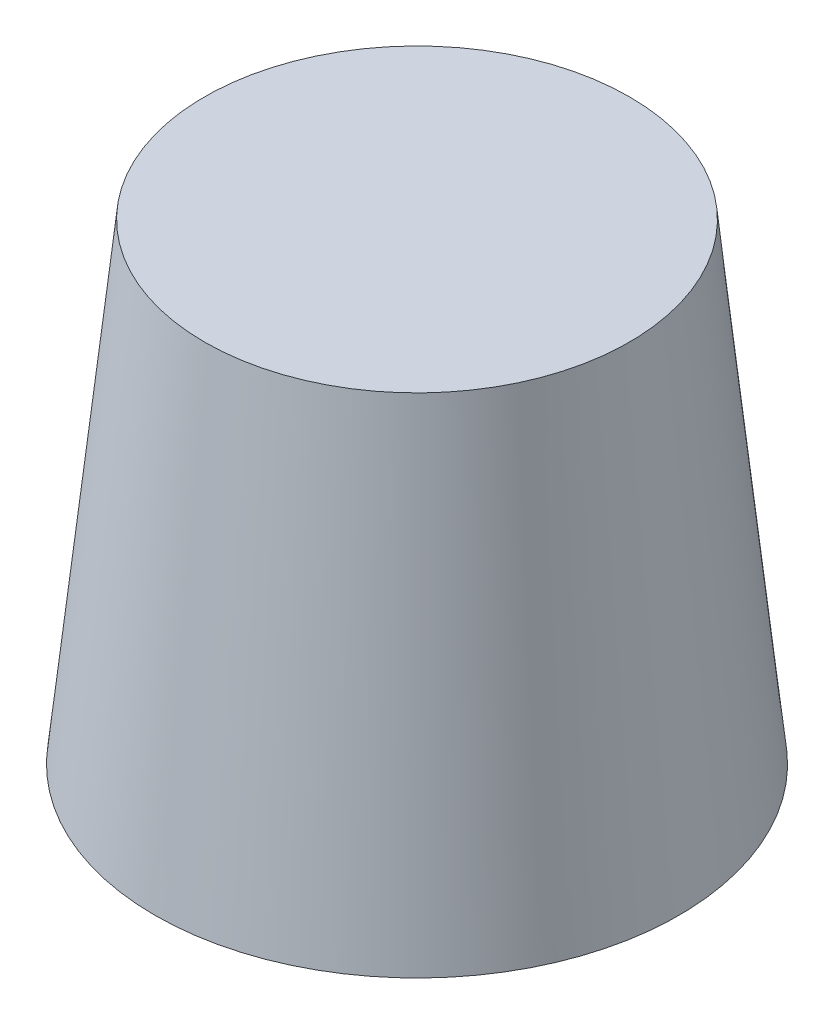
from build123d import *

# Parameters (mm, degrees)
ESQUISSE2_R             = 5
BOSS_EXTRU_1_DEPTH      = 9
BOSS_EXTRU_1_TAPER      = 6
ESQUISSE3_W             = 2.4
ESQUISSE3_H             = 5.4
ENL_V_MAT_EXTRU_1_DEPTH = 7


with BuildPart() as part:
    # Esquisse2 → Boss.-Extru.1 (new body)
    with BuildSketch(Plane(origin=(0, 0, 0), x_dir=(1, 0, 0), z_dir=(0, 1, 0))):
        Circle(ESQUISSE2_R)
    extrude(amount=BOSS_EXTRU_1_DEPTH, taper=BOSS_EXTRU_1_TAPER)

    # Esquisse3 → Enlèv. mat.-Extru.1 (cut)
    with BuildSketch(Plane.XZ):
        Rectangle(ESQUISSE3_W, ESQUISSE3_H)
    extrude(amount=-ENL_V_MAT_EXTRU_1_DEPTH, mode=Mode.SUBTRACT)


solid = part.part
